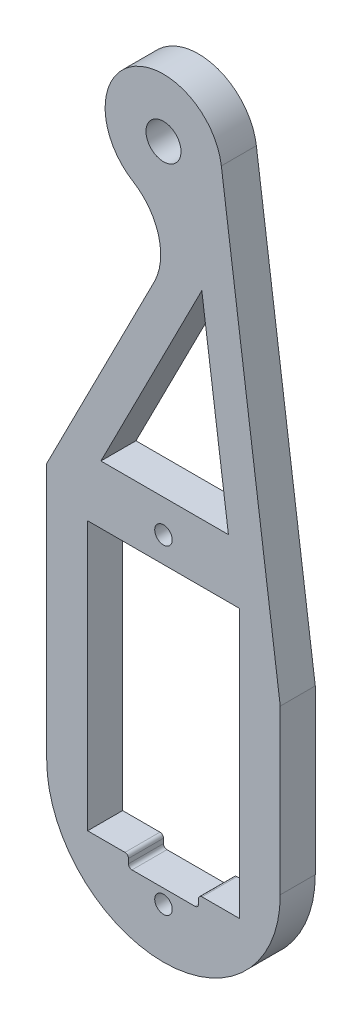
from build123d import *

# Parameters (mm, degrees)
SKETCH_1_R          = 0.75
SKETCH_1_W          = 13
SKETCH_1_H          = 23
SKETCH_1_R_2        = 1.5
EXTRUDE_1_DEPTH     = 1.5
SKETCH_2_W          = 6
SKETCH_2_H          = 1
CUT_EXTRUDE_1_DEPTH = 3
FILLET_1_R          = 0.3


with BuildPart() as part:
    # 草图1 → 凸台-拉伸1 (new body, symmetric)
    with BuildSketch(Plane.XY):
        with BuildLine():
            ThreePointArc((-10, -8), (0, -18), (10, -8))
            Line((10, -8), (10, 6))
            Line((10, 6), (4.955472685, 43.54580062))
            ThreePointArc((4.955472685, 43.54580062), (-2.725773115, 47.071677579), (-2.618575221, 38.62053245))
            ThreePointArc((-2.618575221, 38.62053245), (-0.423906888, 35.714832413), (-0.782117822, 32.091112401))
            Line((-0.782117822, 32.091112401), (-10, 14))
            Line((-10, 14), (-10, -8))
        make_face()
        with Locations((0, -13.7)):
            Circle(SKETCH_1_R, mode=Mode.SUBTRACT)
        Rectangle(SKETCH_1_W, SKETCH_1_H, mode=Mode.SUBTRACT)
        with Locations((0, 13.7)):
            Circle(SKETCH_1_R, mode=Mode.SUBTRACT)
        with Locations((0, 42.88)):
            Circle(SKETCH_1_R_2, mode=Mode.SUBTRACT)
        Polygon((5.562298916, 16.5), (-5.359207663, 16.5), (3.283346167, 33.461966942), align=None, mode=Mode.SUBTRACT)
    extrude(amount=EXTRUDE_1_DEPTH, both=True)

    # 草图2 → 切除-拉伸1 (cut)
    with BuildSketch(Plane.XY.offset(1.5)):
        with Locations((0, -12)):
            Rectangle(SKETCH_2_W, SKETCH_2_H)
    extrude(amount=-CUT_EXTRUDE_1_DEPTH, mode=Mode.SUBTRACT)

    # 圆角1
    fillet_1_edges = [part.edges().sort_by_distance(p)[0] for p in [
        (-3, -11.5, 0),
        (3, -11.5, 0),
        (3, -12.5, 0),
        (-3, -12.5, 0),
    ]]
    fillet(fillet_1_edges, radius=FILLET_1_R)


solid = part.part
